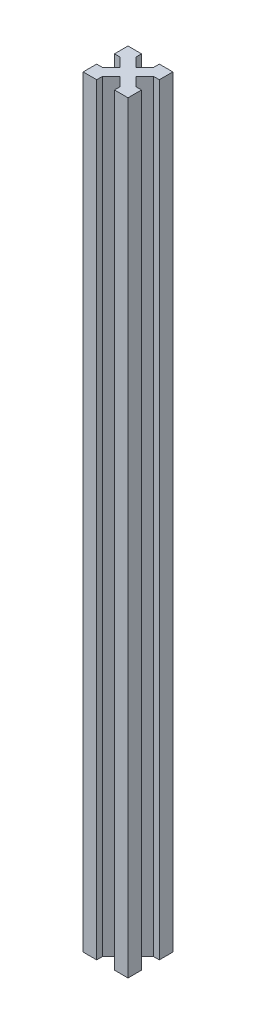
from build123d import *

# Parameters (mm, degrees)
BOSS_EXTRU_1_DEPTH = 340


with BuildPart() as part:
    # Esquisse1 → Boss.-Extru.1 (new body)
    with BuildSketch(Plane(origin=(0, 0, 0), x_dir=(1, 0, 0), z_dir=(0, 1, 0))):
        Polygon((-3.535533906, 0), (-6.035533906, 2.5), (-6.035533906, 0), align=None)
        Polygon((0, 3.535533906), (-2.5, 6.035533906), (-2.5, 2.5), (-6.035533906, 2.5), (-3.535533906, 0), (0, 0), align=None)
        Polygon((0, 6.035533906), (-2.5, 6.035533906), (0, 3.535533906), align=None)
        Polygon((-2.5, 2.5), (-2.5, 6.035533906), (-6.464466094, 10), (-10, 6.464466094), (-6.035533906, 2.5), align=None)
        Polygon((-13.964466094, 0), (-13.964466094, 2.5), (-16.464466094, 0), align=None)
        Polygon((-17.5, 2.5), (-17.5, 6.035533906), (-20, 3.535533906), (-20, 0), (-16.464466094, 0), (-13.964466094, 2.5), align=None)
        Polygon((-20, 3.535533906), (-17.5, 6.035533906), (-20, 6.035533906), align=None)
        Polygon((-10, 6.464466094), (-13.535533906, 10), (-17.5, 6.035533906), (-17.5, 2.5), (-13.964466094, 2.5), align=None)
        Polygon((-6.464466094, 10), (-10, 13.535533906), (-13.535533906, 10), (-10, 6.464466094), align=None)
        Polygon((-2.5, 13.964466094), (-2.5, 17.5), (-6.035533906, 17.5), (-10, 13.535533906), (-6.464466094, 10), align=None)
        Polygon((-6.035533906, 17.5), (-2.5, 17.5), (-2.5, 13.964466094), (0, 16.464466094), (0, 20), (-3.535533906, 20), align=None)
        Polygon((0, 16.464466094), (-2.5, 13.964466094), (0, 13.964466094), align=None)
        Polygon((-6.035533906, 20), (-6.035533906, 17.5), (-3.535533906, 20), align=None)
        Polygon((-16.464466094, 20), (-13.964466094, 17.5), (-13.964466094, 20), align=None)
        Polygon((-17.5, 17.5), (-13.964466094, 17.5), (-16.464466094, 20), (-20, 20), (-20, 16.464466094), (-17.5, 13.964466094), align=None)
        Polygon((-20, 13.964466094), (-17.5, 13.964466094), (-20, 16.464466094), align=None)
        Polygon((-10, 13.535533906), (-13.964466094, 17.5), (-17.5, 17.5), (-17.5, 13.964466094), (-13.535533906, 10), align=None)
    extrude(amount=BOSS_EXTRU_1_DEPTH)


solid = part.part
